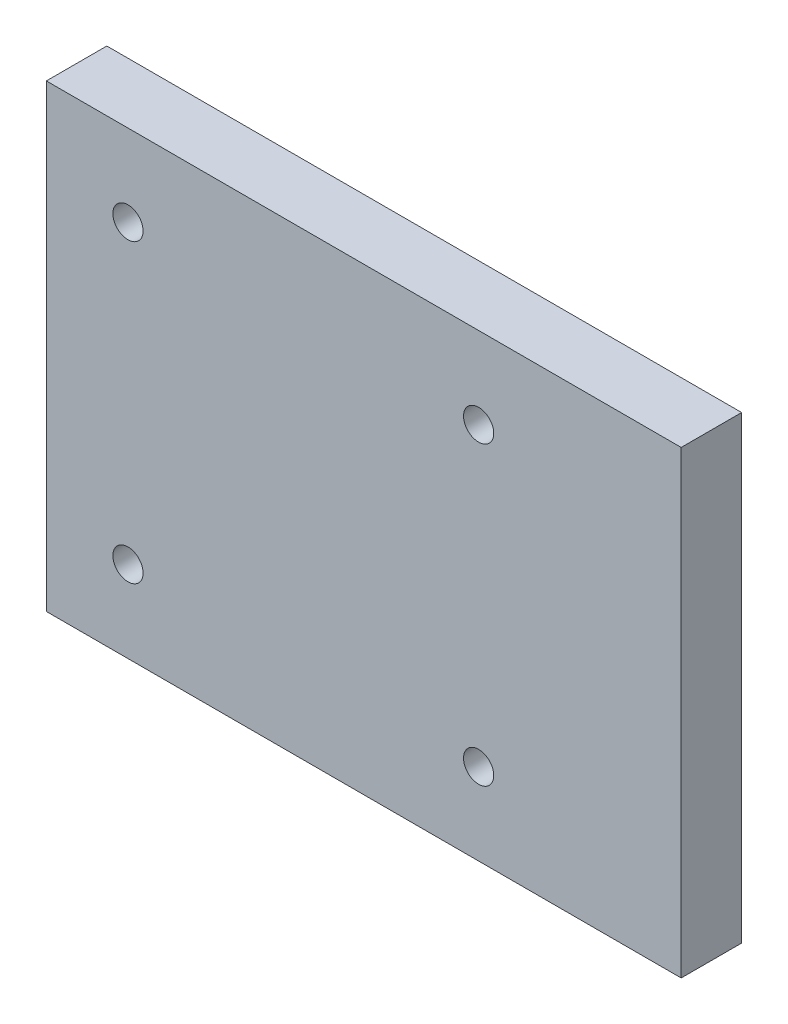
from build123d import *

# Parameters (mm, degrees)
SKETCH1_W           = 105
SKETCH1_H           = 76
SKETCH1_W_2         = 85
SKETCH1_H_2         = 56
SKETCH1_R           = 2.5
BOSS_EXTRUDE1_DEPTH = 10


with BuildPart() as part:
    # Sketch1 → Boss-Extrude1 (new body)
    with BuildSketch(Plane.XY):
        Rectangle(SKETCH1_W, SKETCH1_H)
        Rectangle(SKETCH1_W_2, SKETCH1_H_2, mode=Mode.SUBTRACT)
        Rectangle(SKETCH1_W_2, SKETCH1_H_2)
        with Locations((-39, -24.5)):
            Circle(SKETCH1_R, mode=Mode.SUBTRACT)
        with Locations((19, -24.5)):
            Circle(SKETCH1_R, mode=Mode.SUBTRACT)
        with Locations((-39, 24.5)):
            Circle(SKETCH1_R, mode=Mode.SUBTRACT)
        with Locations((19, 24.5)):
            Circle(SKETCH1_R, mode=Mode.SUBTRACT)
    extrude(amount=BOSS_EXTRUDE1_DEPTH)


solid = part.part
